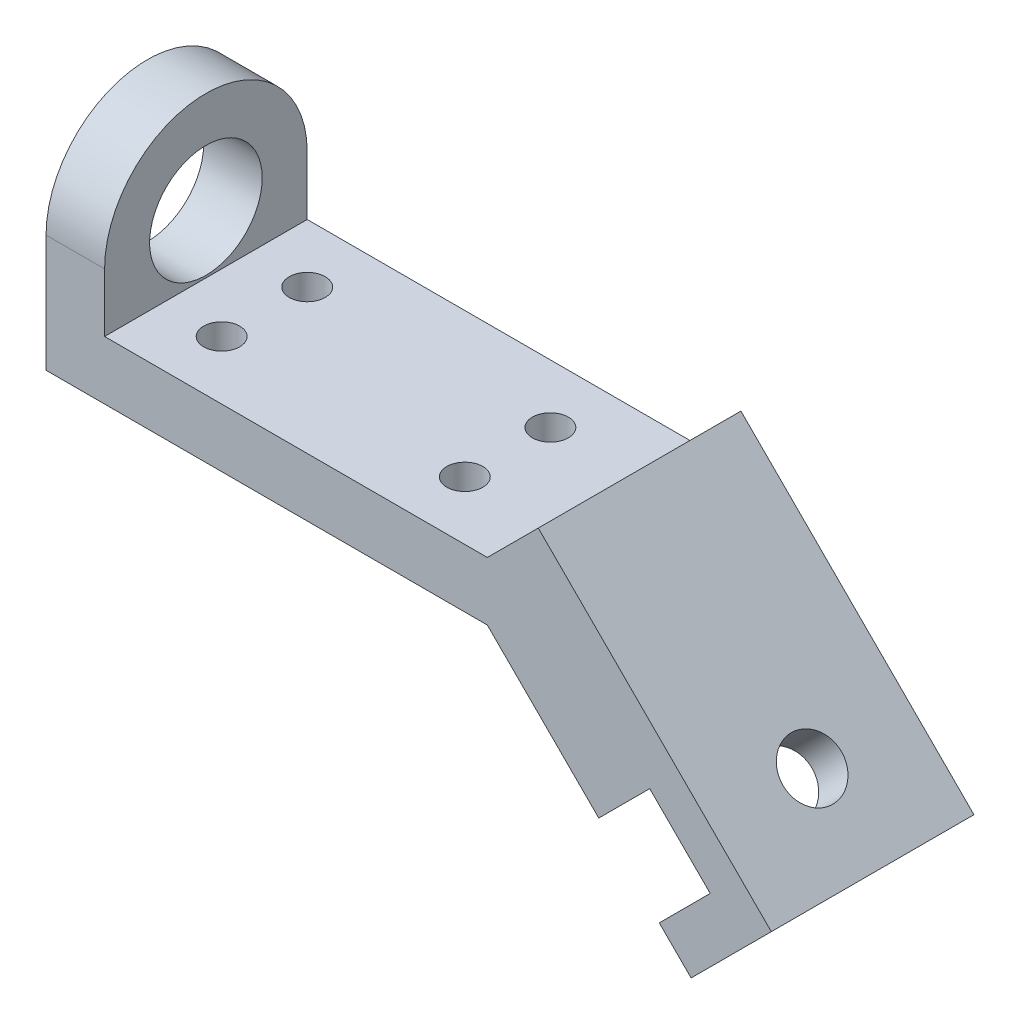
from build123d import *

# Parameters (mm, degrees)
ESTRUSIONE_ESTRUSIONE1_DEPTH  = 22.5
SCHIZZO2_W                    = 45
SCHIZZO2_H                    = 73.192388155
ESTRUSIONE_ESTRUSIONE2_DEPTH  = 16
ESTRUSIONE_ESTRUSIONE3_DEPTH  = 13
TAGLIO_ESTRUSIONE1_DEPTH      = 1
TAGLIO_ESTRUSIONE1_DEPTH_BACK = 46
SCHIZZO5_R                    = 12.5
TAGLIO_ESTRUSIONE2_DEPTH      = 14
SCHIZZO6_R                    = 6.5
TAGLIO_ESTRUSIONE3_DEPTH      = 127.488852712
SCHIZZO7_R                    = 4
TAGLIO_ESTRUSIONE4_DEPTH      = 59.254833996


with BuildPart() as part:
    # Schizzo1 → Estrusione-Estrusione1 (new body, symmetric)
    with BuildSketch(Plane.XY):
        Polygon((-49, 13), (-49, 0), (49, 0), (94.254833996, -45.254833996), (100.754833996, -38.754833996), (49, 13), align=None)
    extrude(amount=ESTRUSIONE_ESTRUSIONE1_DEPTH, both=True)

    # Schizzo2 → Estrusione-Estrusione2 (add)
    with BuildSketch(Plane(origin=(31, 31, 0), x_dir=(0, 0, -1), z_dir=(0.707106781, 0.707106781, 0))):
        with Locations((0, -62.052038201)):
            Rectangle(SCHIZZO2_W, SCHIZZO2_H)
    extrude(amount=ESTRUSIONE_ESTRUSIONE2_DEPTH)

    # Schizzo3 → Estrusione-Estrusione3 (add)
    with BuildSketch(Plane.ZY.offset(49)):
        with BuildLine():
            Line((-22.5, 0), (-22.5, 26))
            ThreePointArc((-22.5, 26), (0, 48.5), (22.5, 26))
            Line((22.5, 26), (22.5, 0))
            Line((22.5, 0), (-22.5, 0))
        make_face()
    extrude(amount=-ESTRUSIONE_ESTRUSIONE3_DEPTH)

    # Schizzo4 → Taglio-Estrusione1 (cut, two sides)
    with BuildSketch(Plane.XY.offset(22.5)) as taglio_estrusione1_sk:
        Polygon((73.748737342, -24.748737342), (85.062445841, -13.435028843), (98.497474683, -26.870057685), (87.183766184, -38.183766184), align=None)
    extrude(amount=TAGLIO_ESTRUSIONE1_DEPTH, mode=Mode.SUBTRACT)
    extrude(taglio_estrusione1_sk.sketch, amount=-TAGLIO_ESTRUSIONE1_DEPTH_BACK, mode=Mode.SUBTRACT)

    # Schizzo5 → Taglio-Estrusione2 (cut, through all)
    with BuildSketch(Plane(origin=(-36, 0, 0), x_dir=(0, 0, -1), z_dir=(1, 0, 0))):
        with Locations((0, 26)):
            Circle(SCHIZZO5_R)
    extrude(amount=-TAGLIO_ESTRUSIONE2_DEPTH, mode=Mode.SUBTRACT)

    # Schizzo6 → Taglio-Estrusione3 (cut, through all)
    with BuildSketch(Plane(origin=(42.313708499, 42.313708499, 0), x_dir=(0, 0, -1), z_dir=(0.707106781, 0.707106781, 0))):
        with Locations((0, -79.648232278)):
            Circle(SCHIZZO6_R)
    extrude(amount=-TAGLIO_ESTRUSIONE3_DEPTH, mode=Mode.SUBTRACT)

    # Schizzo7 → Taglio-Estrusione4 (cut, through all)
    with BuildSketch(Plane(origin=(0, 13, 0), x_dir=(1, 0, 0), z_dir=(0, 1, 0))):
        with Locations((-23, 9.5)):
            Circle(SCHIZZO7_R)
        with Locations((31, 9.5)):
            Circle(SCHIZZO7_R)
    taglio_estrusione4 = extrude(amount=-TAGLIO_ESTRUSIONE4_DEPTH, mode=Mode.SUBTRACT)

    # Specchia1: Taglio-Estrusione4 across plane
    add(taglio_estrusione4.mirror(Plane.XY), mode=Mode.SUBTRACT)


solid = part.part
